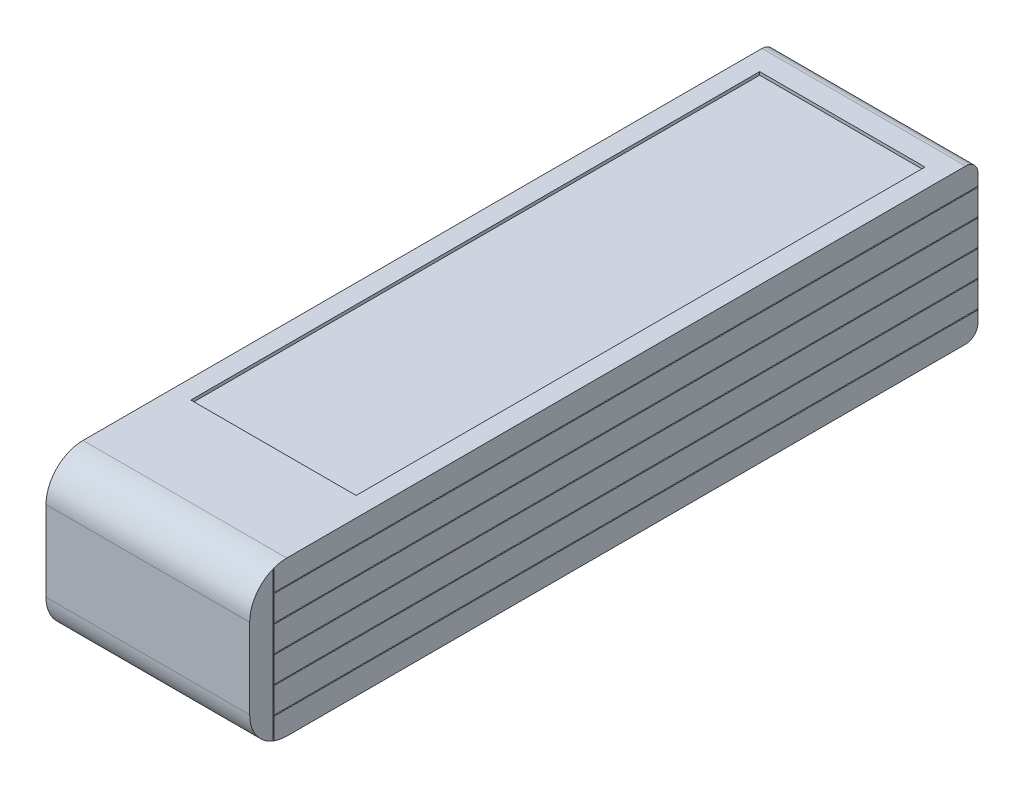
from build123d import *

# Parameters (mm, degrees)
EXTRUDE_1_DEPTH     = 33
SKETCH_2_W          = 113.94546963
SKETCH_2_H          = 0.153731759
SKETCH_2_W_2        = 0.159880439
SKETCH_2_H_2        = 23.946679257
CUT_EXTRUDE_1_DEPTH = 0.5
SKETCH_3_W          = 113.94546963
SKETCH_3_H          = 0.153731759
SKETCH_3_W_2        = 0.186483874
SKETCH_3_H_2        = 23.188530915
CUT_EXTRUDE_2_DEPTH = 0.5
SKETCH_4_W          = 26.780776055
SKETCH_4_H          = 92.160179523
CUT_EXTRUDE_3_DEPTH = 0.5


with BuildPart() as part:
    # 草图1 → 凸台-拉伸1 (new body)
    with BuildSketch(Plane(origin=(0, 0, 0), x_dir=(0, 0, -1), z_dir=(1, 0, 0))):
        with BuildLine():
            Line((-53, 12.5), (57, 12.5))
            ThreePointArc((57, 12.5), (58.414213562, 11.914213562), (59, 10.5))
            Line((59, 10.5), (59, -10.5))
            ThreePointArc((59, -10.5), (58.414213562, -11.914213562), (57, -12.5))
            Line((57, -12.5), (-53, -12.5))
            ThreePointArc((-53, -12.5), (-57.242640687, -10.742640687), (-59, -6.5))
            Line((-59, -6.5), (-59, 6.5))
            ThreePointArc((-59, 6.5), (-57.242640687, 10.742640687), (-53, 12.5))
        make_face()
    extrude(amount=EXTRUDE_1_DEPTH)

    # 草图2 → 切除-拉伸1 (cut)
    with BuildSketch(Plane(origin=(33, 0, 0), x_dir=(0, 0, -1), z_dir=(1, 0, 0))):
        with Locations((1.940270858, 4.299962397)):
            Rectangle(SKETCH_2_W, SKETCH_2_H)
        with Locations((1.940270858, -3.7603e-05)):
            Rectangle(SKETCH_2_W, SKETCH_2_H)
        with Locations((1.940270858, 8.599962398)):
            Rectangle(SKETCH_2_W, SKETCH_2_H)
        with Locations((1.940270858, -4.300037602)):
            Rectangle(SKETCH_2_W, SKETCH_2_H)
        with Locations((1.940270858, -8.600037603)):
            Rectangle(SKETCH_2_W, SKETCH_2_H)
        with Locations((-55.163355852, 0.001170191)):
            Rectangle(SKETCH_2_W_2, SKETCH_2_H_2)
    extrude(amount=-CUT_EXTRUDE_1_DEPTH, mode=Mode.SUBTRACT)

    # 草图3 → 切除-拉伸2 (cut)
    with BuildSketch(Plane.ZY):
        with Locations((-1.632775224, 4.336078297)):
            Rectangle(SKETCH_3_W, SKETCH_3_H)
        with Locations((-1.632775224, 0.036078297)):
            Rectangle(SKETCH_3_W, SKETCH_3_H)
        with Locations((-1.632775224, 8.636078297)):
            Rectangle(SKETCH_3_W, SKETCH_3_H)
        with Locations((-1.632775224, -4.263921704)):
            Rectangle(SKETCH_3_W, SKETCH_3_H)
        with Locations((-1.632775224, -8.563921704)):
            Rectangle(SKETCH_3_W, SKETCH_3_H)
        with Locations((55.767421869, 0.036078296)):
            Rectangle(SKETCH_3_W_2, SKETCH_3_H_2)
    extrude(amount=-CUT_EXTRUDE_2_DEPTH, mode=Mode.SUBTRACT)

    # 草图4 → 切除-拉伸3 (cut)
    with BuildSketch(Plane(origin=(0, 12.5, 0), x_dir=(1, 0, 0), z_dir=(0, 1, 0))):
        with Locations((16.455758173, 7.48146235)):
            Rectangle(SKETCH_4_W, SKETCH_4_H)
    extrude(amount=-CUT_EXTRUDE_3_DEPTH, mode=Mode.SUBTRACT)


solid = part.part
